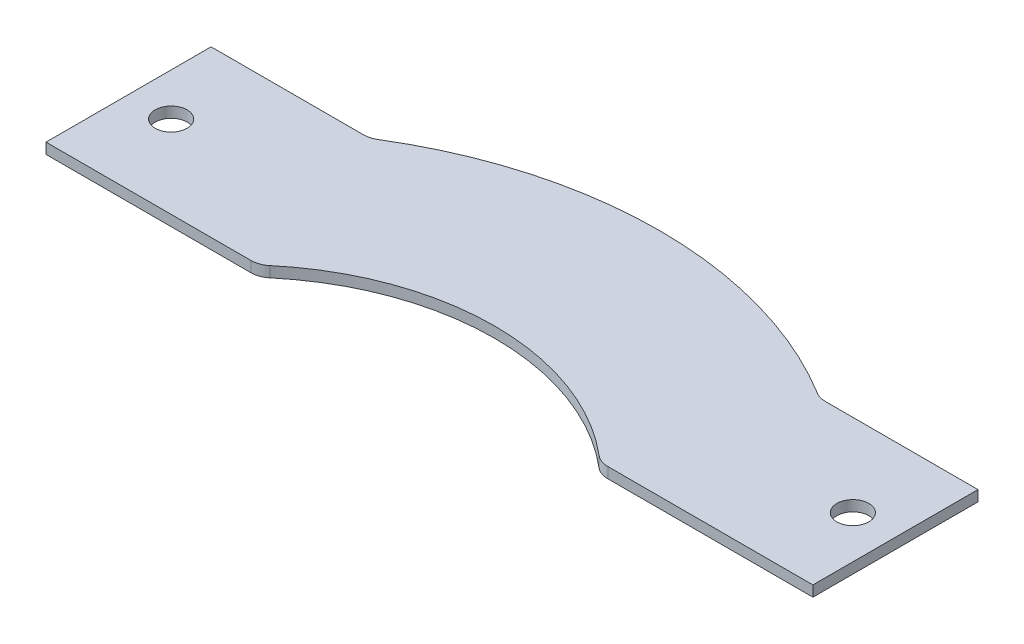
from build123d import *

# Parameters (mm, degrees)
SKETCH1_R      = 4.7625
EXTRUDE1_DEPTH = 3.175


with BuildPart() as part:
    # Sketch1 → Extrude1 (new body)
    with BuildSketch(Plane(origin=(0, 0, 0), x_dir=(1, 0, 0), z_dir=(0, 1, 0))):
        with BuildLine():
            Line((-53.17019082, 56.796126628), (-114.3, 56.796126628))
            Line((-114.3, 56.796126628), (-114.3, 106.008626628))
            Line((-114.3, 106.008626628), (-68.825107544, 106.008626628))
            ThreePointArc((-68.825107544, 106.008626628), (-67.102021241, 106.246877812), (-65.508234891, 106.943753056))
            ThreePointArc((-65.508234891, 106.943753056), (0, 125.4125), (65.508234891, 106.943753056))
            ThreePointArc((65.508234891, 106.943753056), (67.102021241, 106.246877812), (68.825107544, 106.008626628))
            Line((68.825107544, 106.008626628), (114.3, 106.008626628))
            Line((114.3, 106.008626628), (114.3, 56.796126628))
            Line((114.3, 56.796126628), (53.17019082, 56.796126628))
            ThreePointArc((53.17019082, 56.796126628), (50.99326112, 57.180937857), (49.080176141, 58.288732272))
            ThreePointArc((49.080176141, 58.288732272), (0, 76.2), (-49.080176141, 58.288732272))
            ThreePointArc((-49.080176141, 58.288732272), (-50.99326112, 57.180937857), (-53.17019082, 56.796126628))
        make_face()
        with Locations((101.6, 81.402376628)):
            Circle(SKETCH1_R, mode=Mode.SUBTRACT)
        with Locations((-101.6, 81.402376628)):
            Circle(SKETCH1_R, mode=Mode.SUBTRACT)
    extrude(amount=EXTRUDE1_DEPTH)


solid = part.part
